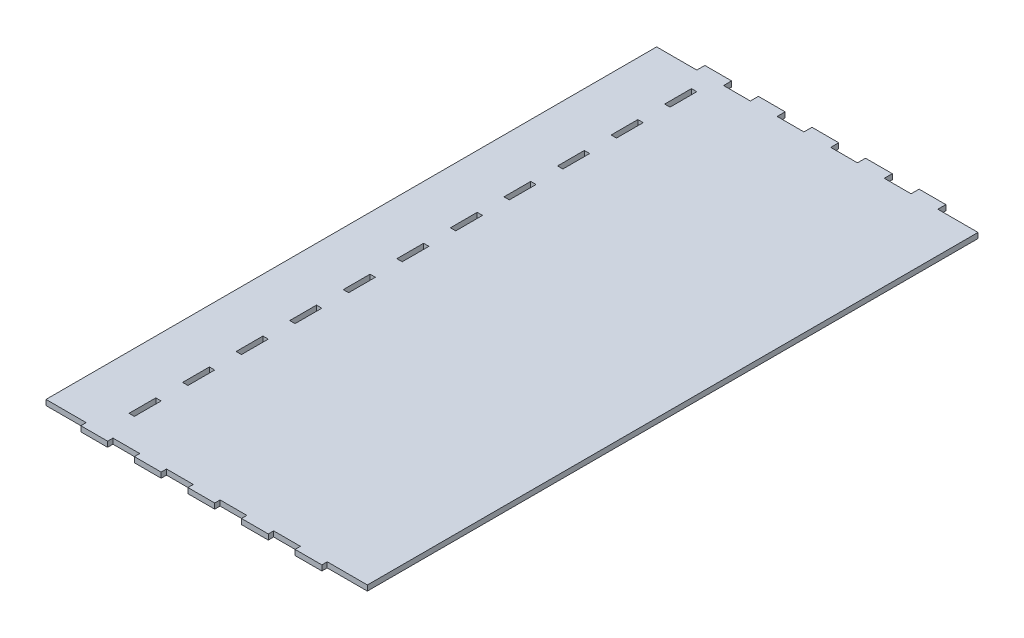
from build123d import *

# Parameters (mm, degrees)
SKETCH1_W           = 120
SKETCH1_H           = 227
BOSS_EXTRUDE1_DEPTH = 2
SKETCH2_W           = 10
SKETCH2_H           = 2
BOSS_EXTRUDE2_DEPTH = 3
LPATTERN1_COUNT     = 5
LPATTERN1_PITCH     = 20
SKETCH3_W           = 10
SKETCH3_H           = 2
BOSS_EXTRUDE3_DEPTH = 3
LPATTERN2_COUNT     = 5
LPATTERN2_PITCH     = 20
SKETCH4_W           = 3
SKETCH4_H           = 10
CUT_EXTRUDE1_DEPTH  = 3
LPATTERN3_COUNT     = 11
LPATTERN3_PITCH     = 20
ESQUISSE1_W         = 1
ESQUISSE1_H         = 210
BOSS_EXTRU_1_DEPTH  = 2
ESQUISSE2_W         = 120
ESQUISSE2_H         = 1
BOSS_EXTRU_2_DEPTH  = 2


with BuildPart() as part:
    # Sketch1 → Boss-Extrude1 (new body)
    with BuildSketch(Plane(origin=(0, 0, 0), x_dir=(1, 0, 0), z_dir=(0, 1, 0))):
        with Locations((60, 113.5)):
            Rectangle(SKETCH1_W, SKETCH1_H)
    extrude(amount=BOSS_EXTRUDE1_DEPTH)

    # Sketch2 → Boss-Extrude2 (add)
    with BuildSketch(Plane.XY):
        with Locations((20, 1)):
            Rectangle(SKETCH2_W, SKETCH2_H)
    boss_extrude2 = extrude(amount=BOSS_EXTRUDE2_DEPTH)

    # LPattern1: Boss-Extrude2 ×5
    with Locations(*[(i * LPATTERN1_PITCH, 0, 0) for i in range(1, LPATTERN1_COUNT)]):
        add(boss_extrude2)

    # Sketch3 → Boss-Extrude3 (add)
    with BuildSketch(Plane(origin=(0, 0, -227), x_dir=(-1, 0, 0), z_dir=(0, 0, -1))):
        with Locations((-100, 1)):
            Rectangle(SKETCH3_W, SKETCH3_H)
    boss_extrude3 = extrude(amount=BOSS_EXTRUDE3_DEPTH)

    # LPattern2: Boss-Extrude3 ×5
    with Locations(*[(-i * LPATTERN2_PITCH, 0, 0) for i in range(1, LPATTERN2_COUNT)]):
        add(boss_extrude3)

    # Sketch4 → Cut-Extrude1 (cut, through all)
    with BuildSketch(Plane(origin=(0, 2, 0), x_dir=(1, 0, 0), z_dir=(0, 1, 0))):
        with Locations((21.5, 15)):
            Rectangle(SKETCH4_W, SKETCH4_H)
    cut_extrude1 = extrude(amount=-CUT_EXTRUDE1_DEPTH, mode=Mode.SUBTRACT)

    # LPattern3: Cut-Extrude1 ×11
    with Locations(*[(0, 0, -i * LPATTERN3_PITCH) for i in range(1, LPATTERN3_COUNT)]):
        add(cut_extrude1, mode=Mode.SUBTRACT)

    # Esquisse1 → Boss.-Extru.1 (add)
    with BuildSketch(Plane(origin=(0, 2, 0), x_dir=(1, 0, 0), z_dir=(0, 1, 0))):
        with Locations((22.5, 115)):
            Rectangle(ESQUISSE1_W, ESQUISSE1_H)
    extrude(amount=-BOSS_EXTRU_1_DEPTH)

    # Esquisse2 → Boss.-Extru.2 (add)
    with BuildSketch(Plane.XZ):
        with Locations((60, 0.5)):
            Rectangle(ESQUISSE2_W, ESQUISSE2_H)
    extrude(amount=-BOSS_EXTRU_2_DEPTH)


solid = part.part
